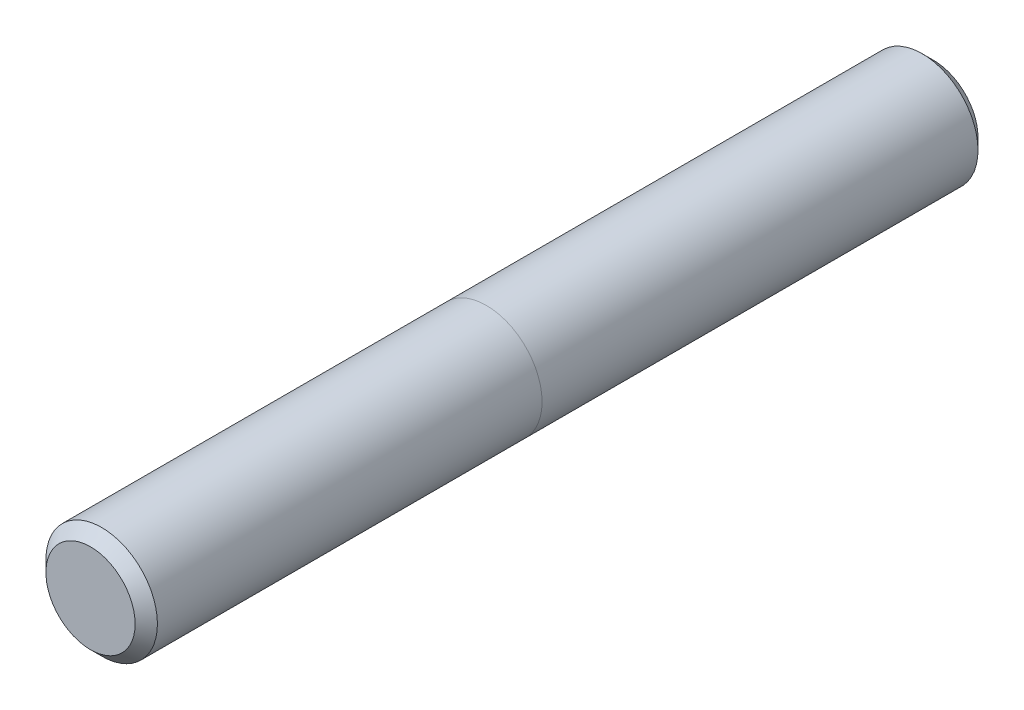
from build123d import *

# Parameters (mm, degrees)
SKETCH3_R           = 7.9375
BOSS_EXTRUDE1_DEPTH = 60
CHAMFER1_SIZE       = 1.5875


with BuildPart() as part:
    # Sketch3 → Boss-Extrude1 (new body, symmetric)
    with BuildSketch(Plane.XY):
        Circle(SKETCH3_R)
    extrude(amount=BOSS_EXTRUDE1_DEPTH, both=True)

    # Chamfer1
    chamfer1_edges = [part.edges().sort_by_distance(p)[0] for p in [
        (-7.9375, 0, -60),
        (-7.9375, 0, 60),
    ]]
    chamfer(chamfer1_edges, length=CHAMFER1_SIZE)


solid = part.part
